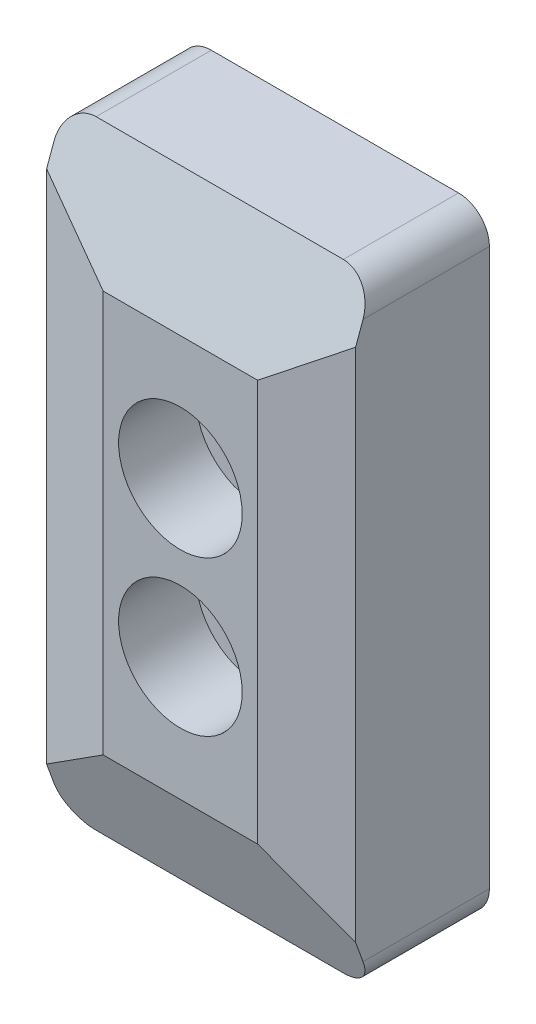
from build123d import *

# Parameters (mm, degrees)
SKETCH1_W           = 20
SKETCH1_H           = 40
SKETCH1_R           = 2.15
BOSS_EXTRUDE1_DEPTH = 10
CHAMFER1_SIZE       = 5
CHAMFER1_SIZE2      = 1.339745962
CHAMFER2_SIZE       = 7
CHAMFER2_SIZE2      = 2.54779164
SKETCH2_R           = 4
CUT_EXTRUDE1_DEPTH  = 5
FILLET1_R           = 2


with BuildPart() as part:
    # Sketch1 → Boss-Extrude1 (new body)
    with BuildSketch(Plane.XY):
        Rectangle(SKETCH1_W, SKETCH1_H)
        with Locations((0, -5)):
            Circle(SKETCH1_R, mode=Mode.SUBTRACT)
        with Locations((0, 5)):
            Circle(SKETCH1_R, mode=Mode.SUBTRACT)
    extrude(amount=BOSS_EXTRUDE1_DEPTH)

    # Chamfer1
    chamfer1_edges = [part.edges().sort_by_distance(p)[0] for p in [
        (-10, 0, 10),
        (10, 0, 10),
    ]]
    chamfer1_side = [part.faces().sort_by_distance(p)[0] for p in [
        (0, 0, 10),
    ]]
    chamfer(chamfer1_edges, length=CHAMFER1_SIZE, length2=CHAMFER1_SIZE2, reference=chamfer1_side[0])

    # Chamfer2
    chamfer2_edges = [part.edges().sort_by_distance(p)[0] for p in [
        (0, -20, 10),
        (0, 20, 10),
    ]]
    chamfer2_side = [part.faces().sort_by_distance(p)[0] for p in [
        (0, 0, 10),
    ]]
    chamfer(chamfer2_edges, length=CHAMFER2_SIZE, length2=CHAMFER2_SIZE2, reference=chamfer2_side[0])

    # Sketch2 → Cut-Extrude1 (cut)
    with BuildSketch(Plane.XY.offset(10)):
        with Locations((0, 5)):
            Circle(SKETCH2_R)
        with Locations((0, -5)):
            Circle(SKETCH2_R)
    extrude(amount=-CUT_EXTRUDE1_DEPTH, mode=Mode.SUBTRACT)

    # Fillet1
    fillet1_edges = [part.edges().sort_by_distance(p)[0] for p in [
        (10, 20, 3.72610418),
        (10, -20, 3.72610418),
        (-10, -20, 3.72610418),
        (-10, 20, 3.72610418),
    ]]
    fillet(fillet1_edges, radius=FILLET1_R)


solid = part.part
